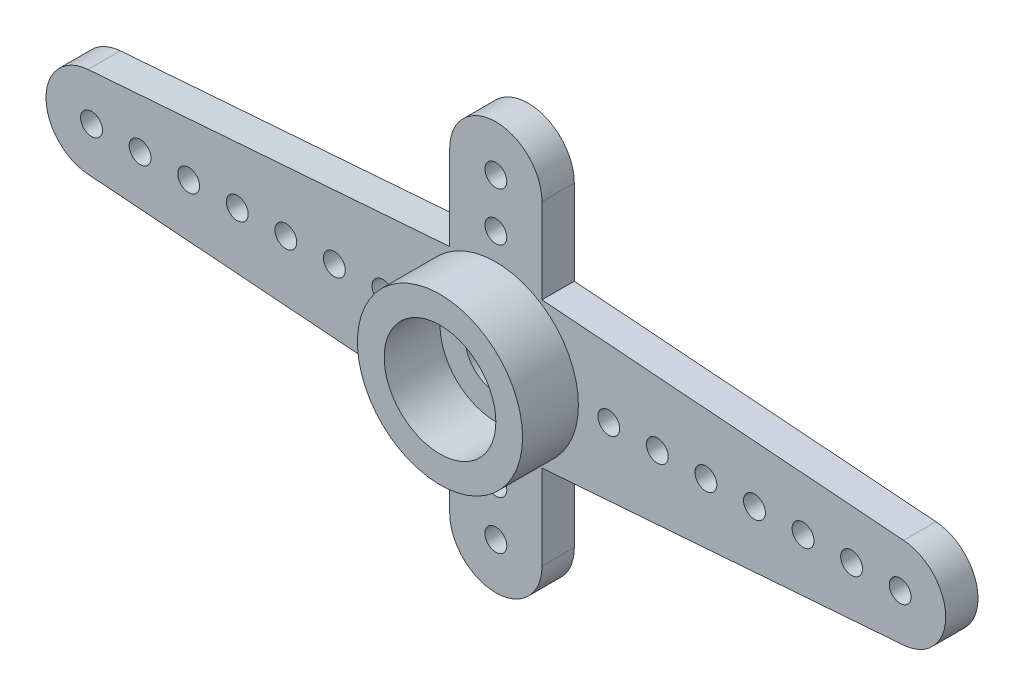
from build123d import *

# Parameters (mm, degrees)
AUFSATZ_LINEAR_AUSTRAGEN1_DEPTH      = 1.33
SKIZZE2_R                            = 3.4
SKIZZE2_R_2                          = 2.3
AUFSATZ_LINEAR_AUSTRAGEN2_DEPTH      = 2.3
AUFSATZ_LINEAR_AUSTRAGEN2_DEPTH_BACK = 1.33
SKIZZE3_R                            = 1.25
SCHNITT_LINEAR_AUSTRAGEN1_DEPTH      = 2.33
SKIZZE4_R                            = 2.35
SCHNITT_LINEAR_AUSTRAGEN2_DEPTH      = 1.1
SKIZZE5_R                            = 0.45
SCHNITT_LINEAR_AUSTRAGEN3_DEPTH      = 2.33


with BuildPart() as part:
    # Skizze1 → Aufsatz-Linear austragen1 (new body)
    with BuildSketch(Plane.XY):
        with BuildLine():
            Line((-16.79191458, 1.869621687), (-1.9, 3))
            Line((-1.9, 3), (-1.9, 6.5))
            ThreePointArc((-1.9, 6.5), (0, 8.4), (1.9, 6.5))
            Line((1.9, 6.5), (1.9, 3))
            Line((1.9, 3), (16.79191458, 1.869621687))
            ThreePointArc((16.79191458, 1.869621687), (18.525, 0), (16.79191458, -1.869621687))
            Line((16.79191458, -1.869621687), (1.9, -3))
            Line((1.9, -3), (1.9, -6.5))
            ThreePointArc((1.9, -6.5), (0, -8.4), (-1.9, -6.5))
            Line((-1.9, -6.5), (-1.9, -3))
            Line((-1.9, -3), (-16.79191458, -1.869621687))
            ThreePointArc((-16.79191458, -1.869621687), (-18.525, 0), (-16.79191458, 1.869621687))
        make_face()
    extrude(amount=AUFSATZ_LINEAR_AUSTRAGEN1_DEPTH)

    # Skizze2 → Aufsatz-Linear austragen2 (add, two sides)
    with BuildSketch(Plane.XY.offset(1.33)) as aufsatz_linear_austragen2_sk:
        Circle(SKIZZE2_R)
        Circle(SKIZZE2_R_2, mode=Mode.SUBTRACT)
    extrude(amount=AUFSATZ_LINEAR_AUSTRAGEN2_DEPTH)
    extrude(aufsatz_linear_austragen2_sk.sketch, amount=-AUFSATZ_LINEAR_AUSTRAGEN2_DEPTH_BACK)

    # Skizze3 → Schnitt-Linear austragen1 (cut, through all)
    with BuildSketch(Plane.XY.offset(1.33)):
        Circle(SKIZZE3_R)
    extrude(amount=-SCHNITT_LINEAR_AUSTRAGEN1_DEPTH, mode=Mode.SUBTRACT)

    # Skizze4 → Schnitt-Linear austragen2 (cut)
    with BuildSketch(Plane(origin=(0, 0, 0), x_dir=(-1, 0, 0), z_dir=(0, 0, -1))):
        Circle(SKIZZE4_R)
    extrude(amount=-SCHNITT_LINEAR_AUSTRAGEN2_DEPTH, mode=Mode.SUBTRACT)

    # Skizze5 → Schnitt-Linear austragen3 (cut, through all)
    with BuildSketch(Plane.XY.offset(1.33)):
        with Locations((0, 6.5)):
            Circle(SKIZZE5_R)
        with Locations((-16.65, 0)):
            Circle(SKIZZE5_R)
        with Locations((0, 4.5)):
            Circle(SKIZZE5_R)
        with Locations((-14.65, 0)):
            Circle(SKIZZE5_R)
        with Locations((-12.65, 0)):
            Circle(SKIZZE5_R)
        with Locations((-10.65, 0)):
            Circle(SKIZZE5_R)
        with Locations((-8.65, 0)):
            Circle(SKIZZE5_R)
        with Locations((-6.65, 0)):
            Circle(SKIZZE5_R)
        with Locations((-4.65, 0)):
            Circle(SKIZZE5_R)
        with Locations((0, -4.5)):
            Circle(SKIZZE5_R)
        with Locations((0, -6.5)):
            Circle(SKIZZE5_R)
        with Locations((4.65, 0)):
            Circle(SKIZZE5_R)
        with Locations((6.65, 0)):
            Circle(SKIZZE5_R)
        with Locations((8.65, 0)):
            Circle(SKIZZE5_R)
        with Locations((10.65, 0)):
            Circle(SKIZZE5_R)
        with Locations((12.65, 0)):
            Circle(SKIZZE5_R)
        with Locations((14.65, 0)):
            Circle(SKIZZE5_R)
        with Locations((16.65, 0)):
            Circle(SKIZZE5_R)
    extrude(amount=-SCHNITT_LINEAR_AUSTRAGEN3_DEPTH, mode=Mode.SUBTRACT)


solid = part.part
